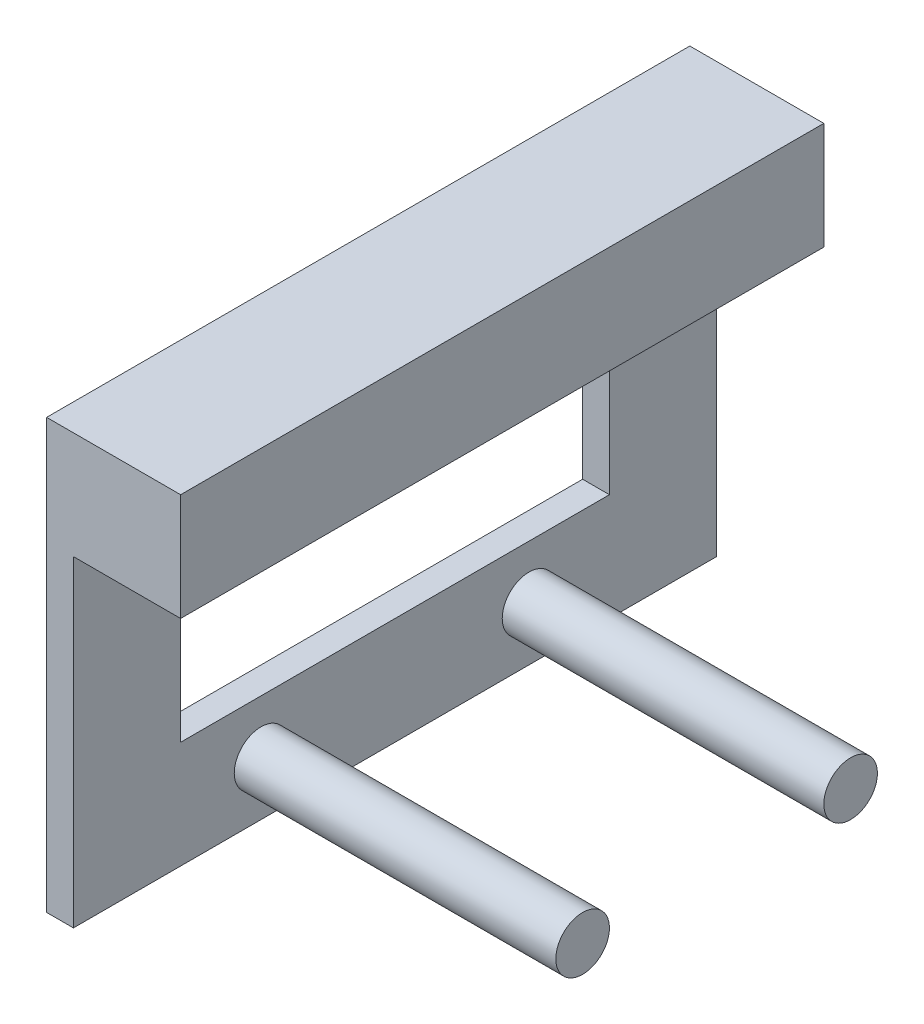
from build123d import *

# Parameters (mm, degrees)
SKETCH2_W           = 80
SKETCH2_H           = 40
BOSS_EXTRUDE1_DEPTH = 7.5
SKETCH3_W           = 80
SKETCH3_H           = 18.5
CUT_EXTRUDE1_DEPTH  = 5
SKETCH9_W           = 80
SKETCH9_H           = 16.5
CUT_EXTRUDE5_DEPTH  = 5
SKETCH10_W          = 20
SKETCH10_H          = 40
CUT_EXTRUDE7_DEPTH  = 10
SKETCH12_W          = 40
SKETCH12_H          = 20
CUT_EXTRUDE8_DEPTH  = 10
SKETCH13_W          = 60
SKETCH13_H          = 5
BOSS_EXTRUDE5_DEPTH = 10
SKETCH14_W          = 60
SKETCH14_H          = 5
BOSS_EXTRUDE6_DEPTH = 5
SKETCH15_R          = 2.5
BOSS_EXTRUDE7_DEPTH = 30


with BuildPart() as part:
    # Sketch2 → Boss-Extrude1 (new body)
    with BuildSketch(Plane(origin=(0, 0, 0), x_dir=(0, 0, -1), z_dir=(1, 0, 0))):
        with Locations((0, 20)):
            Rectangle(SKETCH2_W, SKETCH2_H)
    extrude(amount=BOSS_EXTRUDE1_DEPTH)

    # Sketch3 → Cut-Extrude1 (cut)
    with BuildSketch(Plane(origin=(7.5, 0, 0), x_dir=(0, 0, -1), z_dir=(1, 0, 0))):
        with Locations((0, 9.25)):
            Rectangle(SKETCH3_W, SKETCH3_H)
    extrude(amount=-CUT_EXTRUDE1_DEPTH, mode=Mode.SUBTRACT)

    # Sketch9 → Cut-Extrude5 (cut)
    with BuildSketch(Plane(origin=(7.5, 0, 0), x_dir=(0, 0, -1), z_dir=(1, 0, 0))):
        with Locations((0, 26.75)):
            Rectangle(SKETCH9_W, SKETCH9_H)
    extrude(amount=-CUT_EXTRUDE5_DEPTH, mode=Mode.SUBTRACT)

    # Sketch10 → Cut-Extrude7 (cut)
    with BuildSketch(Plane.ZY):
        with Locations((-30, 20)):
            Rectangle(SKETCH10_W, SKETCH10_H)
    extrude(amount=-CUT_EXTRUDE7_DEPTH, mode=Mode.SUBTRACT)

    # Sketch12 → Cut-Extrude8 (cut)
    with BuildSketch(Plane.ZY):
        with Locations((10, 20)):
            Rectangle(SKETCH12_W, SKETCH12_H)
    extrude(amount=-CUT_EXTRUDE8_DEPTH, mode=Mode.SUBTRACT)

    # Sketch13 → Boss-Extrude5 (add)
    with BuildSketch(Plane(origin=(2.5, 0, 0), x_dir=(0, 0, -1), z_dir=(1, 0, 0))):
        with Locations((-10, 32.5)):
            Rectangle(SKETCH13_W, SKETCH13_H)
    extrude(amount=BOSS_EXTRUDE5_DEPTH)

    # Sketch14 → Boss-Extrude6 (add)
    with BuildSketch(Plane(origin=(7.5, 0, 0), x_dir=(0, 0, -1), z_dir=(1, 0, 0))):
        with Locations((-10, 37.5)):
            Rectangle(SKETCH14_W, SKETCH14_H)
    extrude(amount=BOSS_EXTRUDE6_DEPTH)

    # Sketch15 → Boss-Extrude7 (add)
    with BuildSketch(Plane(origin=(2.5, 0, 0), x_dir=(0, 0, -1), z_dir=(1, 0, 0))):
        with Locations((-22.5, 5)):
            Circle(SKETCH15_R)
        with Locations((2.5, 5)):
            Circle(SKETCH15_R)
    extrude(amount=BOSS_EXTRUDE7_DEPTH)


solid = part.part
